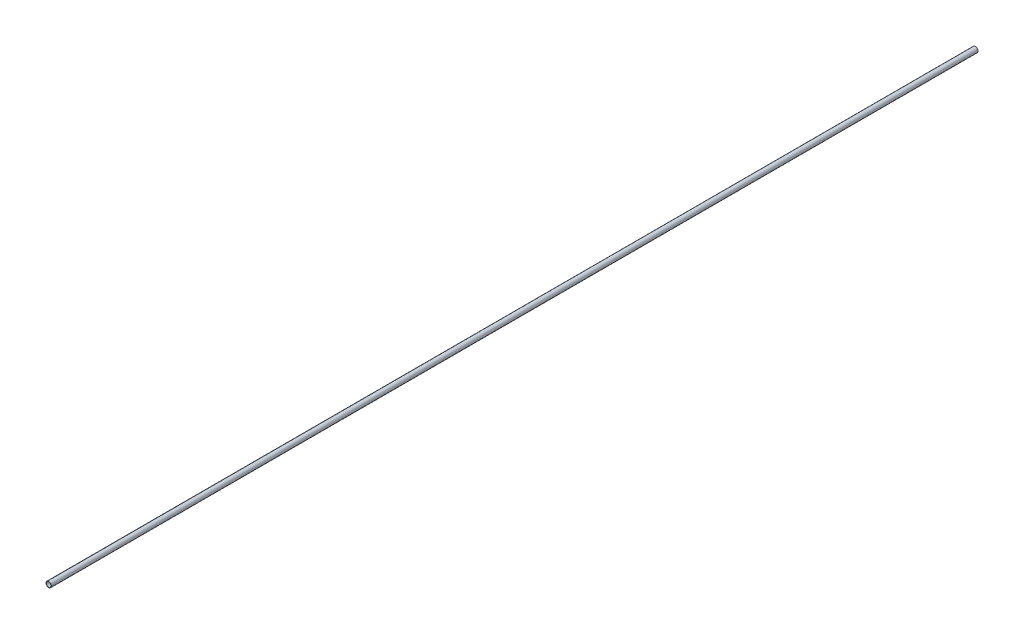
from build123d import *

# Parameters (mm, degrees)
SKETCH1_R           = 6.35
SKETCH1_R_2         = 5.55625
BOSS_EXTRUDE1_DEPTH = 2190.75


with BuildPart() as part:
    # Sketch1 → Boss-Extrude1 (new body)
    with BuildSketch(Plane.XY):
        Circle(SKETCH1_R)
        Circle(SKETCH1_R_2, mode=Mode.SUBTRACT)
    extrude(amount=BOSS_EXTRUDE1_DEPTH)


solid = part.part
